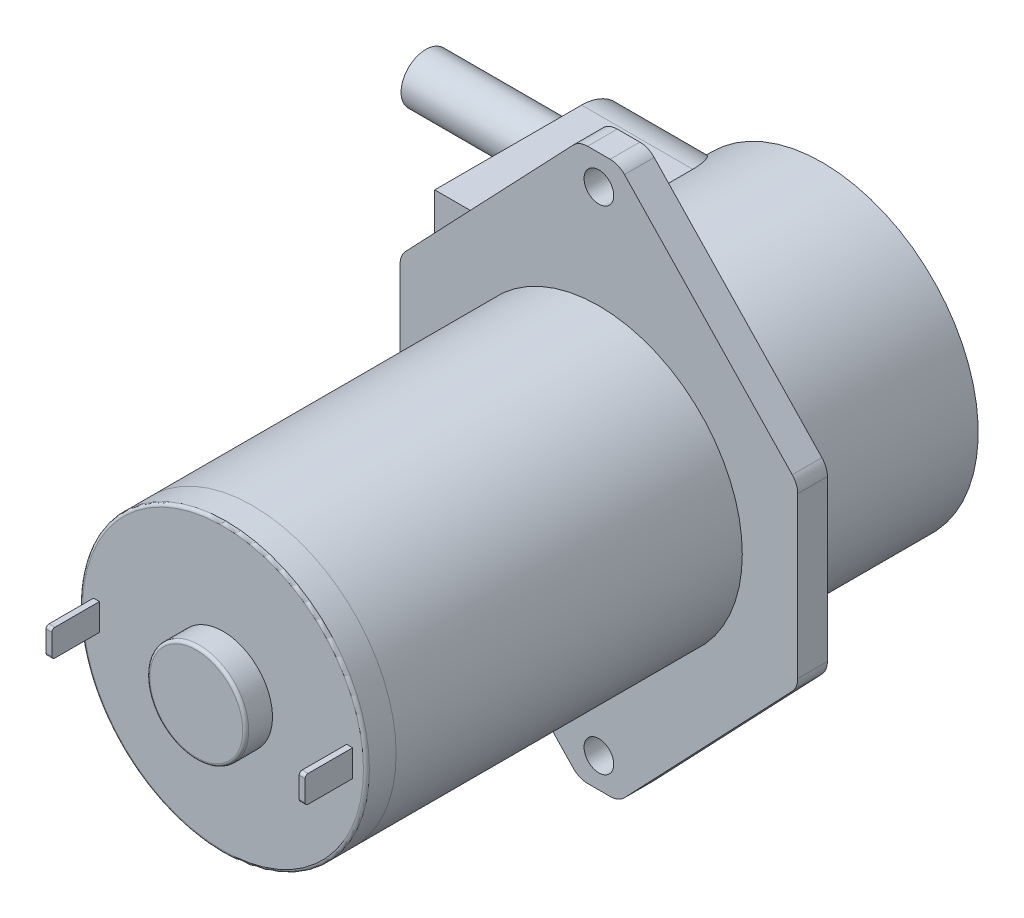
from build123d import *

# Parameters (mm, degrees)
SKETCH1_R               = 14.5
BOSS_EXTRUDE1_DEPTH     = 35
SKETCH3_R               = 14.5
BOSS_EXTRUDE2_DEPTH     = 3
SKETCH5_R               = 5
BOSS_EXTRUDE3_DEPTH     = 2.7
SKETCH6_W               = 0.6
SKETCH6_H               = 2.7
BOSS_EXTRUDE4_DEPTH     = 4.8
FILLET1_R               = 0.3
SKETCH7_R               = 1.5
BOSS_EXTRUDE5_DEPTH     = 3
SKETCH8_R               = 15.75
BOSS_EXTRUDE6_DEPTH     = 19.6
CUT_EXTRUDE1_REACH      = 66.702
CUT_EXTRUDE1_END_RADIUS = 15.75
SKETCH10_R              = 2.5
SKETCH10_R_2            = 1.5
BOSS_EXTRUDE7_DEPTH     = 15


with BuildPart() as part:
    # Sketch1 → Boss-Extrude1 (new body)
    with BuildSketch(Plane.XY):
        Circle(SKETCH1_R)
    extrude(amount=BOSS_EXTRUDE1_DEPTH)

    # Sketch7 → Boss-Extrude5 (add)
    with BuildSketch(Plane.XY):
        with BuildLine():
            Line((19.5480946, 9.47934821), (2.59110728, 27.279500645))
            ThreePointArc((2.59110728, 27.279500645), (1.930730495, 27.738341819), (1.14301268, 27.9))
            Line((1.14301268, 27.9), (-1.14301268, 27.9))
            ThreePointArc((-1.14301268, 27.9), (-1.930730495, 27.738341819), (-2.59110728, 27.279500645))
            Line((-2.59110728, 27.279500645), (-19.5480946, 9.47934821))
            ThreePointArc((-19.5480946, 9.47934821), (-19.956904575, 8.842750924), (-20.1, 8.099847565))
            Line((-20.1, 8.099847565), (-20.1, -8.099847565))
            ThreePointArc((-20.1, -8.099847565), (-19.956904575, -8.842750924), (-19.5480946, -9.47934821))
            Line((-19.5480946, -9.47934821), (-2.59110728, -27.279500645))
            ThreePointArc((-2.59110728, -27.279500645), (-1.930730495, -27.738341819), (-1.14301268, -27.9))
            Line((-1.14301268, -27.9), (1.14301268, -27.9))
            ThreePointArc((1.14301268, -27.9), (1.930730495, -27.738341819), (2.59110728, -27.279500645))
            Line((2.59110728, -27.279500645), (19.5480946, -9.47934821))
            ThreePointArc((19.5480946, -9.47934821), (19.956904575, -8.842750924), (20.1, -8.099847565))
            Line((20.1, -8.099847565), (20.1, 8.099847565))
            ThreePointArc((20.1, 8.099847565), (19.956904575, 8.842750924), (19.5480946, 9.47934821))
        make_face()
        with Locations((0, 24.9)):
            Circle(SKETCH7_R, mode=Mode.SUBTRACT)
        with Locations(Location((0, -24.9, 0), (0, 0, 180))):
            Circle(SKETCH7_R, mode=Mode.SUBTRACT)
    extrude(amount=-BOSS_EXTRUDE5_DEPTH)

    # Sketch8 → Boss-Extrude6 (add)
    with BuildSketch(Plane(origin=(0, 0, -3), x_dir=(-1, 0, 0), z_dir=(0, 0, -1))):
        Circle(SKETCH8_R)
        with BuildLine():
            Line((15.27219696, 3.85), (19.6, 3.85))
            Line((19.6, 3.85), (19.6, 13.35))
            Line((19.6, 13.35), (8.357032966, 13.35))
            ThreePointArc((8.357032966, 13.35), (12.733720067, 9.269027633), (15.27219696, 3.85))
        make_face()
        with BuildLine():
            Line((19.6, -3.85), (15.27219696, -3.85))
            ThreePointArc((15.27219696, -3.85), (12.733720067, -9.269027633), (8.357032966, -13.35))
            Line((8.357032966, -13.35), (19.6, -13.35))
            Line((19.6, -13.35), (19.6, -3.85))
        make_face()
    extrude(amount=BOSS_EXTRUDE6_DEPTH)

    # Cut-Extrude1: up to this cylinder (the profile starts outside it)
    cut_extrude1_end = Plane(origin=(0, 0, -21.539002), z_dir=(0, 0, 1)) * Cylinder(CUT_EXTRUDE1_END_RADIUS, 165.904, mode=Mode.PRIVATE)
    # Sketch9 → Cut-Extrude1 (cut, up to the surface)
    with BuildSketch(Plane.ZY.offset(19.6), mode=Mode.PRIVATE) as cut_extrude1_sk1:
        with BuildLine():
            Line((-17.85, 13.35), (-22.6, 13.35))
            Line((-22.6, 13.35), (-22.6, 8.6))
            ThreePointArc((-22.6, 8.6), (-21.208757211, 11.958757211), (-17.85, 13.35))
        make_face()
    cut_extrude1_tool1 = extrude(cut_extrude1_sk1.sketch, amount=-CUT_EXTRUDE1_REACH, mode=Mode.PRIVATE) - cut_extrude1_end
    add(cut_extrude1_tool1.solids().sort_by_distance((-19.6, 12.289002, -21.539002))[0], mode=Mode.SUBTRACT)
    # Sketch9 → Cut-Extrude1 (cut, up to the surface)
    with BuildSketch(Plane.ZY.offset(19.6), mode=Mode.PRIVATE) as cut_extrude1_sk2:
        with BuildLine():
            ThreePointArc((-17.85, 3.85), (-21.208757211, 5.241242789), (-22.6, 8.6))
            Line((-22.6, 8.6), (-22.6, 3.85))
            Line((-22.6, 3.85), (-17.85, 3.85))
        make_face()
    cut_extrude1_tool2 = extrude(cut_extrude1_sk2.sketch, amount=-CUT_EXTRUDE1_REACH, mode=Mode.PRIVATE) - cut_extrude1_end
    add(cut_extrude1_tool2.solids().sort_by_distance((-19.6, 4.910998, -21.539002))[0], mode=Mode.SUBTRACT)
    # Sketch9 → Cut-Extrude1 (cut, up to the surface)
    with BuildSketch(Plane.ZY.offset(19.6), mode=Mode.PRIVATE) as cut_extrude1_sk3:
        with BuildLine():
            ThreePointArc((-22.6, -8.6), (-21.208757211, -5.241242789), (-17.85, -3.85))
            Line((-17.85, -3.85), (-22.6, -3.85))
            Line((-22.6, -3.85), (-22.6, -8.6))
        make_face()
    cut_extrude1_tool3 = extrude(cut_extrude1_sk3.sketch, amount=-CUT_EXTRUDE1_REACH, mode=Mode.PRIVATE) - cut_extrude1_end
    add(cut_extrude1_tool3.solids().sort_by_distance((-19.6, -4.910998, -21.539002))[0], mode=Mode.SUBTRACT)
    # Sketch9 → Cut-Extrude1 (cut, up to the surface)
    with BuildSketch(Plane.ZY.offset(19.6), mode=Mode.PRIVATE) as cut_extrude1_sk4:
        with BuildLine():
            ThreePointArc((-17.85, -13.35), (-21.208757211, -11.958757211), (-22.6, -8.6))
            Line((-22.6, -8.6), (-22.6, -13.35))
            Line((-22.6, -13.35), (-17.85, -13.35))
        make_face()
    cut_extrude1_tool4 = extrude(cut_extrude1_sk4.sketch, amount=-CUT_EXTRUDE1_REACH, mode=Mode.PRIVATE) - cut_extrude1_end
    add(cut_extrude1_tool4.solids().sort_by_distance((-19.6, -12.289002, -21.539002))[0], mode=Mode.SUBTRACT)

    # Sketch10 → Boss-Extrude7 (add)
    with BuildSketch(Plane.ZY.offset(19.6)):
        with Locations((-17.1, 8.6)):
            Circle(SKETCH10_R)
        with Locations((-17.1, 8.6)):
            Circle(SKETCH10_R_2, mode=Mode.SUBTRACT)
        with Locations(Location((-17.1, -8.6, 0), (0, 0, 180))):
            Circle(SKETCH10_R)
        with Locations((-17.1, -8.6)):
            Circle(SKETCH10_R_2, mode=Mode.SUBTRACT)
    extrude(amount=BOSS_EXTRUDE7_DEPTH)


with BuildPart() as body_2:
    # Sketch3 → Boss-Extrude2 (new body)
    with BuildSketch(Plane.XY.offset(35)):
        Circle(SKETCH3_R)
    extrude(amount=BOSS_EXTRUDE2_DEPTH)

    # Sketch5 → Boss-Extrude3 (add)
    with BuildSketch(Plane(origin=(0, 0, 38), x_dir=(-1, 0, 0), z_dir=(0, 0, -1))):
        Circle(SKETCH5_R)
    extrude(amount=-BOSS_EXTRUDE3_DEPTH)

    # Sketch6 → Boss-Extrude4 (add)
    with BuildSketch(Plane(origin=(0, 0, 38), x_dir=(-1, 0, 0), z_dir=(0, 0, -1))):
        with Locations((-12.8, 0)):
            Rectangle(SKETCH6_W, SKETCH6_H)
        with Locations((12.8, 0)):
            Rectangle(SKETCH6_W, SKETCH6_H)
    extrude(amount=-BOSS_EXTRUDE4_DEPTH)

    # Fillet1
    fillet1_edges = [body_2.edges().sort_by_distance(p)[0] for p in [
        (12.8, 1.35, 42.8),
        (12.8, -1.35, 42.8),
        (-12.8, -1.35, 42.8),
        (-12.8, 1.35, 42.8),
        (-14.5, 0, 38),
        (5, 0, 40.7),
    ]]
    fillet(fillet1_edges, radius=FILLET1_R)


solid = Compound([part.part, body_2.part])
